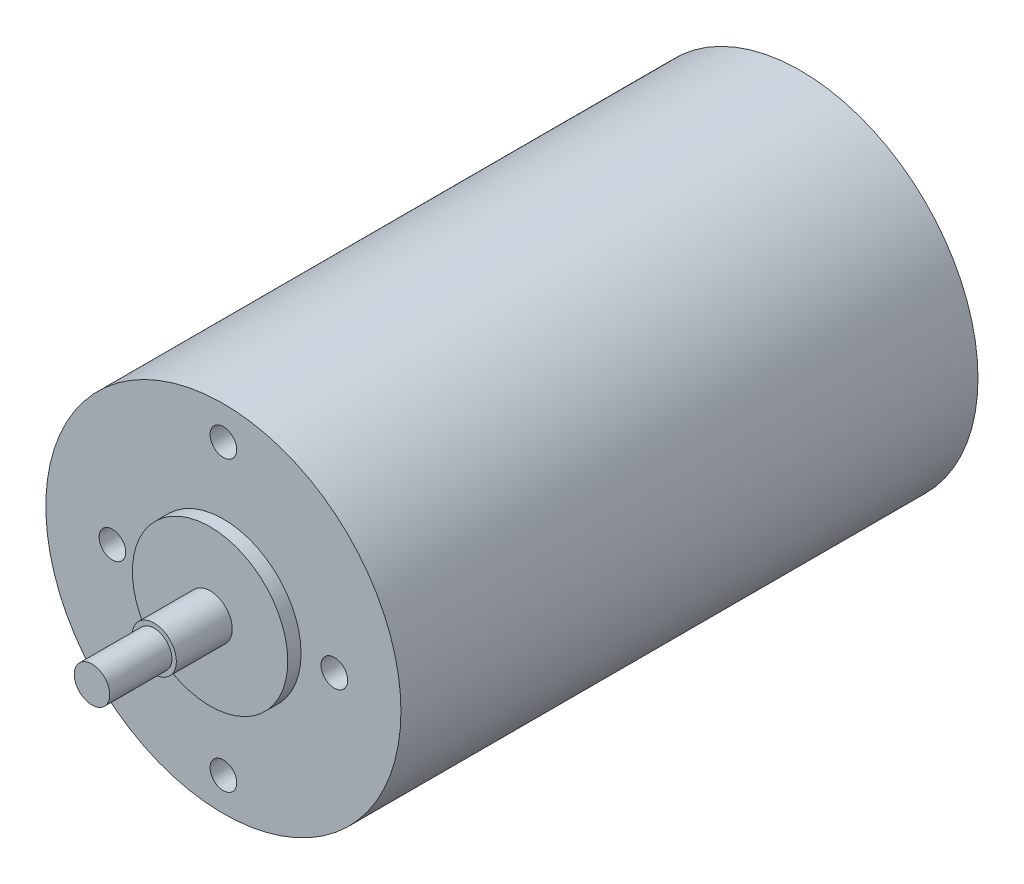
from build123d import *

# Parameters (mm, degrees)
SKETCH_3_R          = 20
EXTRUDE_1_DEPTH     = 65
SKETCH_4_R          = 8.75
EXTRUDE_2_DEPTH     = 1.5
SKETCH_6_R          = 8.75
EXTRUDE_3_DEPTH     = 1.5
SKETCH_7_R          = 2.5
EXTRUDE_4_DEPTH     = 6.3
SKETCH_8_R          = 2
EXTRUDE_5_DEPTH     = 7
SKETCH_10_R         = 2.5
EXTRUDE_6_DEPTH     = 1
SKETCH_11_R         = 1.5
CUT_EXTRUDE_1_DEPTH = 4
SKETCH_12_R         = 1.5
CUT_EXTRUDE_2_DEPTH = 4


with BuildPart() as part:
    # 草圖3 → 填料-伸長1 (new body)
    with BuildSketch(Plane.XY):
        Circle(SKETCH_3_R)
    extrude(amount=EXTRUDE_1_DEPTH)

    # 草圖4 → 填料-伸長2 (add)
    with BuildSketch(Plane(origin=(0, 0, 0), x_dir=(-1, 0, 0), z_dir=(0, 0, -1))):
        Circle(SKETCH_4_R)
    extrude(amount=EXTRUDE_2_DEPTH)

    # 草圖6 → 填料-伸長3 (add)
    with BuildSketch(Plane.XY.offset(65)):
        Circle(SKETCH_6_R)
    extrude(amount=EXTRUDE_3_DEPTH)

    # 草圖7 → 填料-伸長4 (add)
    with BuildSketch(Plane.XY.offset(66.5)):
        Circle(SKETCH_7_R)
    extrude(amount=EXTRUDE_4_DEPTH)

    # 草圖8 → 填料-伸長5 (add)
    with BuildSketch(Plane.XY.offset(72.8)):
        Circle(SKETCH_8_R)
    extrude(amount=EXTRUDE_5_DEPTH)

    # 草圖10 → 填料-伸長6 (add)
    with BuildSketch(Plane(origin=(0, 0, -1.5), x_dir=(-1, 0, 0), z_dir=(0, 0, -1))):
        Circle(SKETCH_10_R)
    extrude(amount=EXTRUDE_6_DEPTH)

    # 草圖11 → 除料-伸長1 (cut)
    with BuildSketch(Plane.XY.offset(65)):
        with Locations((-12.5, 0)):
            Circle(SKETCH_11_R)
        with Locations((12.5, 0)):
            Circle(SKETCH_11_R)
    extrude(amount=-CUT_EXTRUDE_1_DEPTH, mode=Mode.SUBTRACT)

    # 草圖12 → 除料-伸長2 (cut)
    with BuildSketch(Plane.XY.offset(65)):
        with Locations((0, 16.25)):
            Circle(SKETCH_12_R)
        with Locations((0, -16.25)):
            Circle(SKETCH_12_R)
    extrude(amount=-CUT_EXTRUDE_2_DEPTH, mode=Mode.SUBTRACT)


solid = part.part
